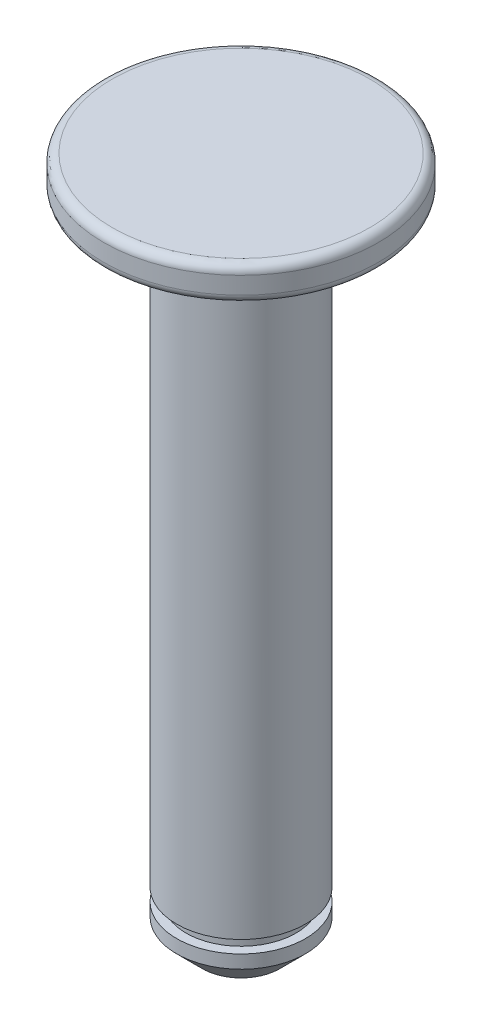
from build123d import *

# Parameters (mm, degrees)
SKETCH1_R           = 8
BOSS_EXTRUDE1_DEPTH = 2
SKETCH2_R           = 3.75
BOSS_EXTRUDE2_DEPTH = 38
RIB2_REACH          = 43.569
SKETCH3_WALL_W      = 87.966865888
SKETCH3_WALL_H      = 2
SKETCH5_W           = 2
SKETCH5_H           = 0.73
FILLET1_R           = 0.5
CHAMFER1_SIZE       = 1.5


with BuildPart() as part:
    # Sketch1 → Boss-Extrude1 (new body)
    with BuildSketch(Plane(origin=(0, 0, 0), x_dir=(1, 0, 0), z_dir=(0, 1, 0))):
        with Locations(Location((0, 0, 0), (0, 0, 270))):
            Circle(SKETCH1_R)
    extrude(amount=-BOSS_EXTRUDE1_DEPTH)

    # Sketch2 → Boss-Extrude2 (add)
    with BuildSketch(Plane.XZ.offset(2)):
        with Locations(Location((0, 0, 0), (0, 0, 270))):
            Circle(SKETCH2_R)
    extrude(amount=BOSS_EXTRUDE2_DEPTH)

    # Sketch3 wall → Rib2 (add, up to next)
    with BuildSketch(Plane(origin=(4.75, -3, 0), x_dir=(-0.707106781187, -0.707106781187, 0), z_dir=(0.707106781187, -0.707106781187, 0)), mode=Mode.PRIVATE) as rib2_sk1:
        Rectangle(SKETCH3_WALL_W, SKETCH3_WALL_H)
    rib2_tool1 = extrude(rib2_sk1.sketch, amount=-RIB2_REACH, mode=Mode.PRIVATE) - part.part
    add(rib2_tool1.solids().sort_by_distance((4.75, -3, 0))[0])

    # Sketch5 → Cut-Revolve1 (revolve, cut)
    with BuildSketch(Plane(origin=(0, 0, 0), x_dir=(0, 0, -1), z_dir=(1, 0, 0))):
        with Locations((4.2, -37.365)):
            Rectangle(SKETCH5_W, SKETCH5_H)
    revolve(axis=Axis((0, -40, 0), (0, 1, 0)), mode=Mode.SUBTRACT)

    # Fillet1
    fillet1_edges = [part.edges().sort_by_distance(p)[0] for p in [
        (0, 0, -8),
        (0, -2, -8),
    ]]
    fillet(fillet1_edges, radius=FILLET1_R)

    # Chamfer1
    chamfer1_edges = [part.edges().sort_by_distance(p)[0] for p in [
        (0, -40, 3.75),
    ]]
    chamfer(chamfer1_edges, length=CHAMFER1_SIZE)


solid = part.part
